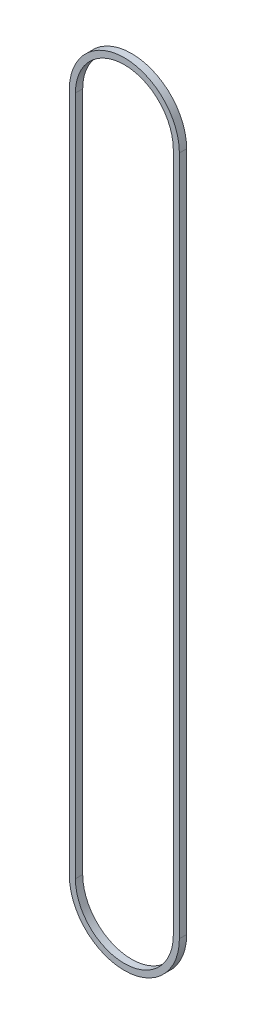
from build123d import *

# Parameters (mm, degrees)
BOSS_EXTRUDE1_DEPTH = 7.62


with BuildPart() as part:
    # Sketch1 → Boss-Extrude1 (new body)
    with BuildSketch(Plane.XY):
        with BuildLine():
            Line((-57.4929, 0), (-57.4929, 711.2))
            ThreePointArc((-57.4929, 711.2), (0, 768.6929), (57.4929, 711.2))
            Line((57.4929, 711.2), (57.4929, 0))
            ThreePointArc((57.4929, 0), (0, -57.4929), (-57.4929, 0))
        make_face()
        with BuildLine():
            Line((-51.1429, 0), (-51.1429, 711.2))
            ThreePointArc((-51.1429, 711.2), (0, 762.3429), (51.1429, 711.2))
            Line((51.1429, 711.2), (51.1429, 0))
            ThreePointArc((51.1429, 0), (0, -51.1429), (-51.1429, 0))
        make_face(mode=Mode.SUBTRACT)
    extrude(amount=BOSS_EXTRUDE1_DEPTH)


solid = part.part
